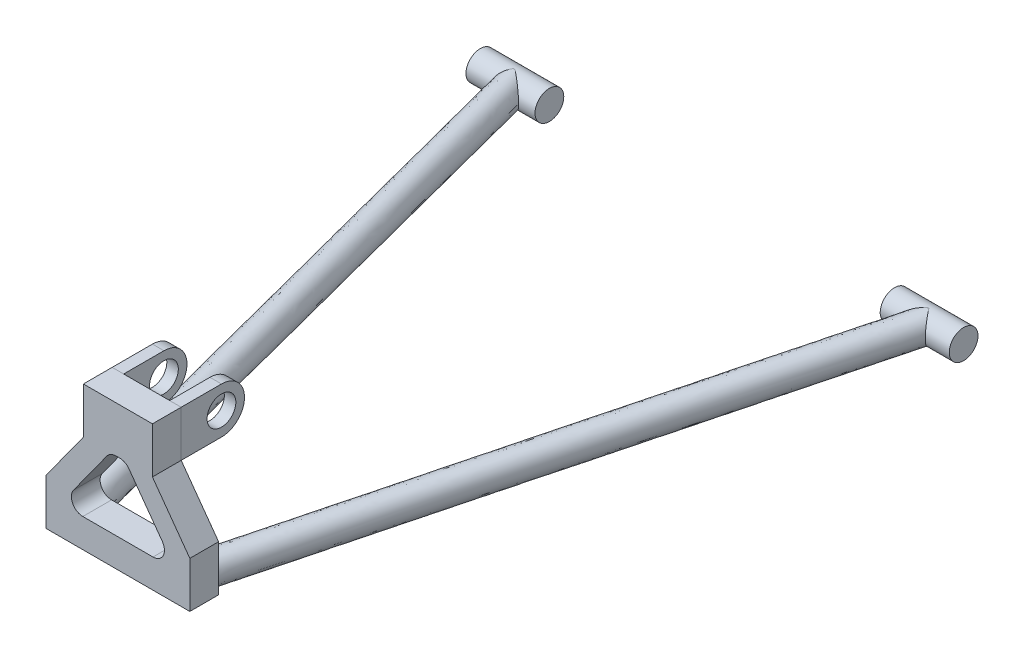
from build123d import *

# Parameters (mm, degrees)
SKETCH16_R              = 2.5
BOSS_EXTRUDE1_DEPTH     = 103.324730825
SKETCH16_3_R            = 2.5
BOSS_EXTRUDE2_DEPTH     = 103.324730825
SKETCH17_R              = 2.5
CUT_EXTRUDE2_DEPTH      = 108.18442051
CUT_EXTRUDE2_DEPTH_BACK = 108.18442051
BOSS_EXTRUDE4_START     = 30
SKETCH17_3_R            = 2.5
BOSS_EXTRUDE4_DEPTH     = 12
BOSS_EXTRUDE5_START     = -42
SKETCH17_4_R            = 2.5
BOSS_EXTRUDE5_DEPTH     = 12
BOSS_EXTRUDE7_START     = 100
BOSS_EXTRUDE7_DEPTH     = 5
SKETCH23_W              = 2
SKETCH23_H              = 8
BOSS_EXTRUDE8_DEPTH     = 11
BOSS_EXTRUDE8_2_DEPTH   = 11
SKETCH24_R              = 2.5
CUT_EXTRUDE5_DEPTH      = 118.623339521
CUT_EXTRUDE5_DEPTH_BACK = 118.623339521


with BuildPart() as part:
    # Sketch16 → Boss-Extrude1 (new, along a direction that is not the sketch's normal)
    with BuildSketch(Plane.XY):
        with Locations((36, 0)):
            Circle(SKETCH16_R)
    extrude(amount=BOSS_EXTRUDE1_DEPTH, dir=(-0.25163385176495107, 0, 0.967822506788272))


with BuildPart() as body_2:
    # Sketch16_3 → Boss-Extrude2 (new, along a direction that is not the sketch's normal)
    with BuildSketch(Plane.XY):
        with Locations((-36, 0)):
            Circle(SKETCH16_3_R)
    extrude(amount=BOSS_EXTRUDE2_DEPTH, dir=(0.25163385176495107, 0, 0.967822506788272))


with BuildPart() as cut_extrude2_tool:
    # Sketch17 → Cut-Extrude2 (new, two sides)
    with BuildSketch(Plane(origin=(0, 0, 0), x_dir=(0, 0, -1), z_dir=(1, 0, 0))) as cut_extrude2_sk:
        Circle(SKETCH17_R)
    extrude(amount=CUT_EXTRUDE2_DEPTH)
    extrude(cut_extrude2_sk.sketch, amount=-CUT_EXTRUDE2_DEPTH_BACK)


with BuildPart() as part_1:
    add(part.part)

    # Cut-Extrude2: cut by cut_extrude2_tool
    add(cut_extrude2_tool.part, mode=Mode.SUBTRACT)


with BuildPart() as body_2_1:
    add(body_2.part)

    # Cut-Extrude2: cut by cut_extrude2_tool
    add(cut_extrude2_tool.part, mode=Mode.SUBTRACT)


with BuildPart() as body_3:
    # Sketch17_3 → Boss-Extrude4 (new body)
    with BuildSketch(Plane(origin=(0, 0, 0), x_dir=(0, 0, -1), z_dir=(1, 0, 0)).offset(BOSS_EXTRUDE4_START)):
        Circle(SKETCH17_3_R)
    extrude(amount=BOSS_EXTRUDE4_DEPTH)


with BuildPart() as body_4:
    # Sketch17_4 → Boss-Extrude5 (new body)
    with BuildSketch(Plane(origin=(0, 0, 0), x_dir=(0, 0, -1), z_dir=(1, 0, 0)).offset(BOSS_EXTRUDE5_START)):
        Circle(SKETCH17_4_R)
    extrude(amount=BOSS_EXTRUDE5_DEPTH)


with BuildPart() as body_5:
    # Sketch22 → Boss-Extrude7 (new body)
    with BuildSketch(Plane.XY.offset(BOSS_EXTRUDE7_START)):
        Polygon((-12.5, -2.5), (12.5, -2.5), (12.5, 5.5), (6, 14.5), (6, 22.5), (-6, 22.5), (-6, 14.5), (-12.5, 5.5), align=None)
        with BuildLine():
            Line((-6.098190951, 2.5), (6.098190951, 2.5))
            ThreePointArc((6.098190951, 2.5), (7.874498779, 3.586792782), (7.715527659, 5.663115549))
            Line((7.715527659, 5.663115549), (1.930584047, 13.673037473))
            ThreePointArc((1.930584047, 13.673037473), (1.221493595, 14.28126879), (0.313247339, 14.5))
            Line((0.313247339, 14.5), (-0.313247339, 14.5))
            ThreePointArc((-0.313247339, 14.5), (-1.221493595, 14.28126879), (-1.930584047, 13.673037473))
            Line((-1.930584047, 13.673037473), (-7.715527659, 5.663115549))
            ThreePointArc((-7.715527659, 5.663115549), (-7.874498779, 3.586792782), (-6.098190951, 2.5))
        make_face(mode=Mode.SUBTRACT)
    extrude(amount=BOSS_EXTRUDE7_DEPTH)


with BuildPart() as body_6:
    # Sketch23 → Boss-Extrude8 (new body)
    with BuildSketch(Plane(origin=(0, 0, 100), x_dir=(-1, 0, 0), z_dir=(0, 0, -1))):
        with Locations((-5, 18.5)):
            Rectangle(SKETCH23_W, SKETCH23_H)
    extrude(amount=BOSS_EXTRUDE8_DEPTH)


with BuildPart() as body_7:
    # Sketch23 → Boss-Extrude8 2 (new body)
    with BuildSketch(Plane(origin=(0, 0, 100), x_dir=(-1, 0, 0), z_dir=(0, 0, -1))):
        with Locations((5, 18.5)):
            Rectangle(SKETCH23_W, SKETCH23_H)
    extrude(amount=BOSS_EXTRUDE8_2_DEPTH)


with BuildPart() as cut_extrude5_tool:
    # Sketch24 → Cut-Extrude5 (new, two sides)
    with BuildSketch(Plane.ZY.offset(6)) as cut_extrude5_sk:
        with Locations(Location((93, 18.5, 0), (0, 0, 90))):
            Circle(SKETCH24_R)
        with BuildLine():
            Line((93, 22.5), (86, 22.5))
            Line((86, 22.5), (86, 14.5))
            Line((86, 14.5), (93, 14.5))
            ThreePointArc((93, 14.5), (89, 18.5), (93, 22.5))
        make_face()
    extrude(amount=CUT_EXTRUDE5_DEPTH)
    extrude(cut_extrude5_sk.sketch, amount=-CUT_EXTRUDE5_DEPTH_BACK)


with BuildPart() as body_6_1:
    add(body_6.part)

    # Cut-Extrude5: cut by cut_extrude5_tool
    add(cut_extrude5_tool.part, mode=Mode.SUBTRACT)


with BuildPart() as body_7_1:
    add(body_7.part)

    # Cut-Extrude5: cut by cut_extrude5_tool
    add(cut_extrude5_tool.part, mode=Mode.SUBTRACT)


solid = Compound([part_1.part, body_2_1.part, body_3.part, body_4.part, body_5.part, body_6_1.part, body_7_1.part])
